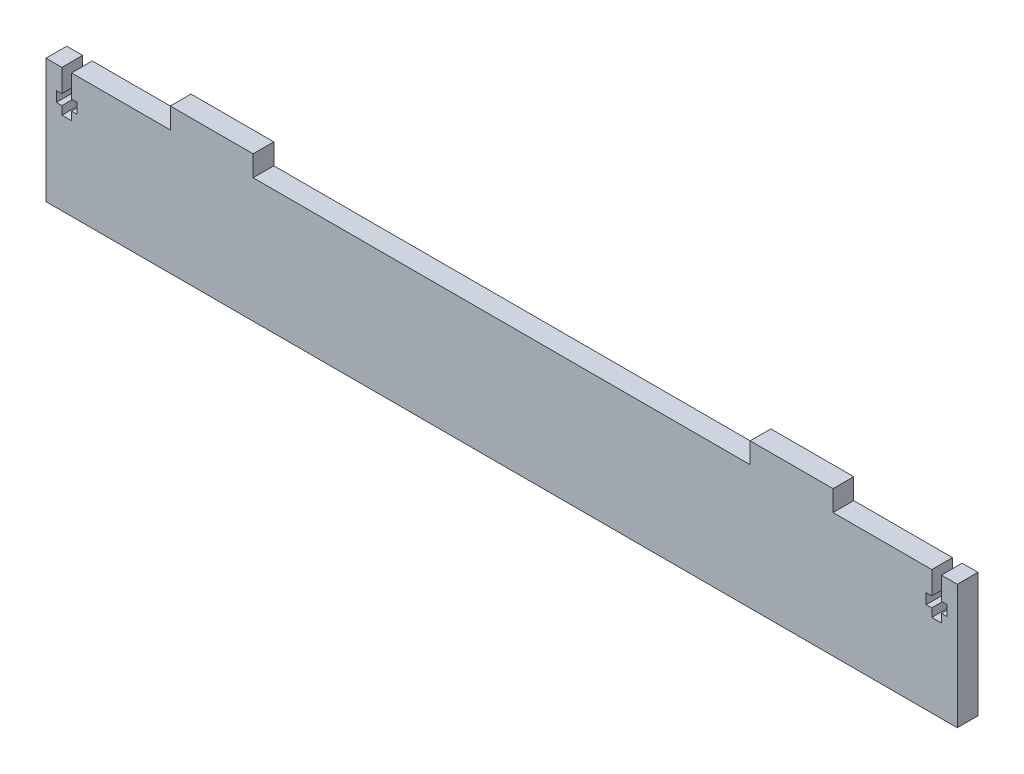
from build123d import *

# Parameters (mm, degrees)
BOSS_EXTRUDE1_DEPTH = 6.35
CUT_EXTRUDE1_DEPTH  = 6.35


with BuildPart() as part:
    # Sketch1 → Boss-Extrude1 (new body)
    with BuildSketch(Plane.XY):
        Polygon((-101.6, 19.05), (-101.6, 25.4), (-76.2, 25.4), (-76.2, 19.05), (76.2, 19.05), (76.2, 25.4), (101.6, 25.4), (101.6, 19.05), (139.7, 19.05), (139.7, -19.05), (-139.7, -19.05), (-139.7, 19.05), align=None)
    extrude(amount=BOSS_EXTRUDE1_DEPTH)

    # Sketch2 → Cut-Extrude1 (cut)
    with BuildSketch(Plane.XY.offset(6.35)):
        Polygon((-134.8232, 19.05), (-134.8232, 12.065), (-136.525, 12.065), (-136.525, 8.89), (-134.8232, 8.89), (-134.8232, 6.35), (-131.8768, 6.35), (-131.8768, 8.89), (-130.175, 8.89), (-130.175, 12.065), (-131.8768, 12.065), (-131.8768, 19.05), align=None)
        Polygon((131.8768, 12.065), (131.8768, 19.05), (134.8232, 19.05), (134.8232, 12.065), (136.525, 12.065), (136.525, 8.89), (134.8232, 8.89), (134.8232, 6.35), (131.8768, 6.35), (131.8768, 8.89), (130.175, 8.89), (130.175, 12.065), align=None)
    extrude(amount=-CUT_EXTRUDE1_DEPTH, mode=Mode.SUBTRACT)


solid = part.part
